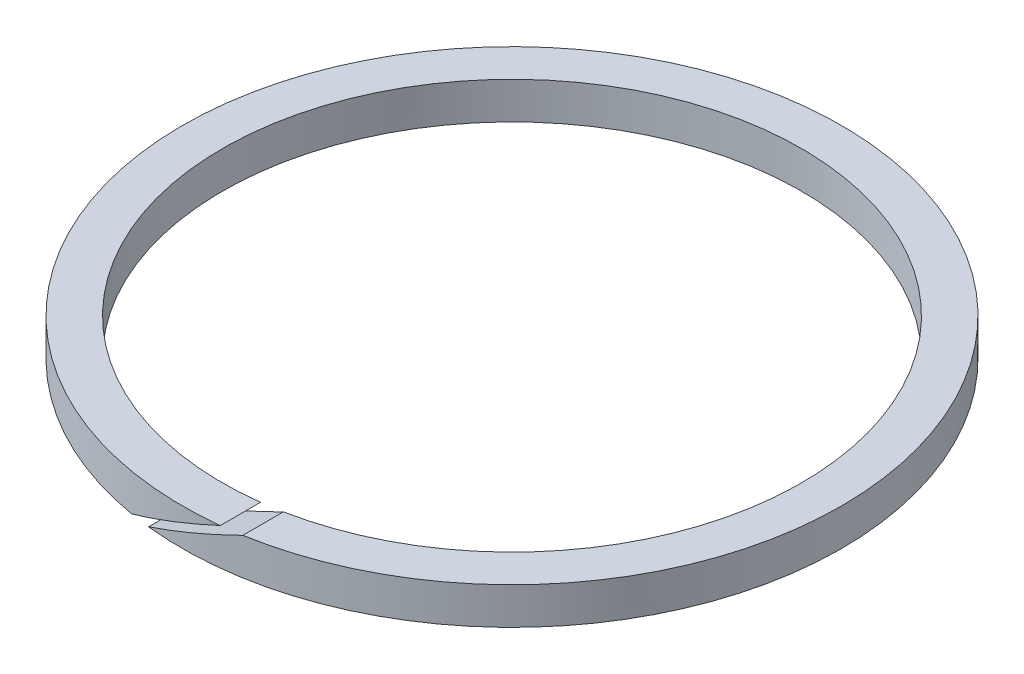
from build123d import *

# Parameters (mm, degrees)
SKETCH3_R                = 11.0998
SKETCH3_R_2              = 9.7536
BOSS_EXTRUDE1_DEPTH      = 0.6223
BOSS_EXTRUDE1_DEPTH_BACK = 0.6223
CUT_EXTRUDE1_DEPTH       = 12.0998


with BuildPart() as part:
    # Sketch3 → Boss-Extrude1 (new body, two sides)
    with BuildSketch(Plane(origin=(0, 0, 0), x_dir=(1, 0, 0), z_dir=(0, 1, 0))) as boss_extrude1_sk:
        Circle(SKETCH3_R)
        Circle(SKETCH3_R_2, mode=Mode.SUBTRACT)
    extrude(amount=BOSS_EXTRUDE1_DEPTH)
    extrude(boss_extrude1_sk.sketch, amount=-BOSS_EXTRUDE1_DEPTH_BACK)

    # Sketch4 → Cut-Extrude1 (cut, through all)
    with BuildSketch(Plane.XY):
        Polygon((2.838309027, 1.280985718), (-2.9315561, -1.050191113), (-2.838309027, -1.280985718), (2.9315561, 1.050191113), align=None)
    extrude(amount=CUT_EXTRUDE1_DEPTH, mode=Mode.SUBTRACT)


solid = part.part
